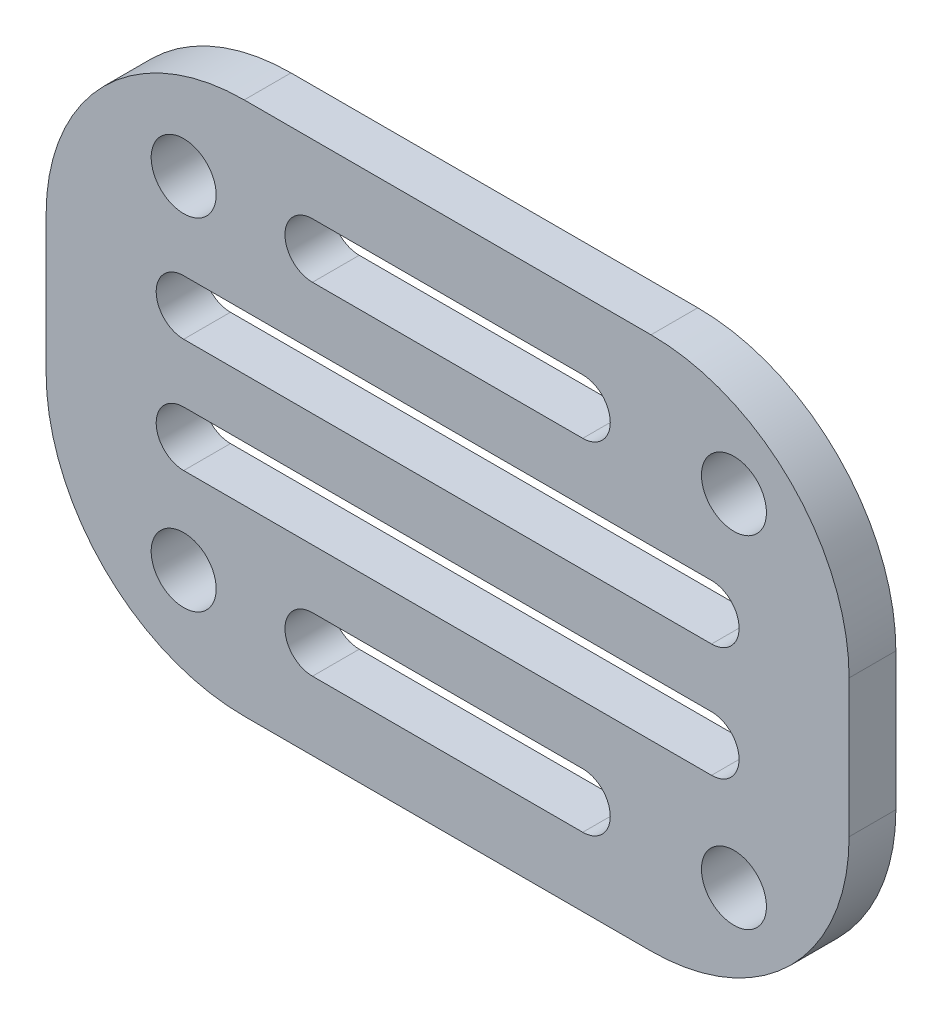
from build123d import *

# Parameters (mm, degrees)
SKETCH1_R           = 1.5
BOSS_EXTRUDE1_DEPTH = 2.159
CUT_EXTRUDE1_DEPTH  = 3.159


with BuildPart() as part:
    # Sketch1 → Boss-Extrude1 (new body)
    with BuildSketch(Plane.XY):
        with BuildLine():
            Line((-9.906, 12.319), (8.872225801, 12.319))
            ThreePointArc((8.872225801, 12.319), (15.338010208, 9.640784407), (18.016225801, 3.175))
            Line((18.016225801, 3.175), (18.016225801, -3.175))
            ThreePointArc((18.016225801, -3.175), (15.338010208, -9.640784407), (8.872225801, -12.319))
            Line((8.872225801, -12.319), (-9.906, -12.319))
            ThreePointArc((-9.906, -12.319), (-16.371784407, -9.640784407), (-19.05, -3.175))
            Line((-19.05, -3.175), (-19.05, 3.175))
            ThreePointArc((-19.05, 3.175), (-16.371784407, 9.640784407), (-9.906, 12.319))
        make_face()
        with Locations((-12.7, 7.874)):
            Circle(SKETCH1_R, mode=Mode.SUBTRACT)
        with Locations((-12.7, -7.874)):
            Circle(SKETCH1_R, mode=Mode.SUBTRACT)
        with Locations((12.7, 7.874)):
            Circle(SKETCH1_R, mode=Mode.SUBTRACT)
        with Locations((12.7, -7.874)):
            Circle(SKETCH1_R, mode=Mode.SUBTRACT)
    extrude(amount=BOSS_EXTRUDE1_DEPTH)

    # Sketch4 → Cut-Extrude1 (cut, through all)
    with BuildSketch(Plane.XY.offset(2.159)):
        with BuildLine():
            Line((-6.755, 9.144), (5.721225801, 9.144))
            ThreePointArc((5.721225801, 9.144), (6.991225801, 7.874), (5.721225801, 6.604))
            Line((5.721225801, 6.604), (-6.755, 6.604))
            ThreePointArc((-6.755, 6.604), (-8.025, 7.874), (-6.755, 9.144))
        make_face()
        with BuildLine():
            Line((-12.7, 3.894666667), (11.666225801, 3.894666667))
            ThreePointArc((11.666225801, 3.894666667), (12.936225801, 2.624666667), (11.666225801, 1.354666667))
            Line((11.666225801, 1.354666667), (-12.7, 1.354666667))
            ThreePointArc((-12.7, 1.354666667), (-13.97, 2.624666667), (-12.7, 3.894666667))
        make_face()
        with BuildLine():
            Line((-12.7, -1.354666667), (11.666225801, -1.354666667))
            ThreePointArc((11.666225801, -1.354666667), (12.936225801, -2.624666667), (11.666225801, -3.894666667))
            Line((11.666225801, -3.894666667), (-12.7, -3.894666667))
            ThreePointArc((-12.7, -3.894666667), (-13.97, -2.624666667), (-12.7, -1.354666667))
        make_face()
        with BuildLine():
            Line((-6.755, -6.604), (5.721225801, -6.604))
            ThreePointArc((5.721225801, -6.604), (6.991225801, -7.874), (5.721225801, -9.144))
            Line((5.721225801, -9.144), (-6.755, -9.144))
            ThreePointArc((-6.755, -9.144), (-8.025, -7.874), (-6.755, -6.604))
        make_face()
    extrude(amount=-CUT_EXTRUDE1_DEPTH, mode=Mode.SUBTRACT)


solid = part.part
